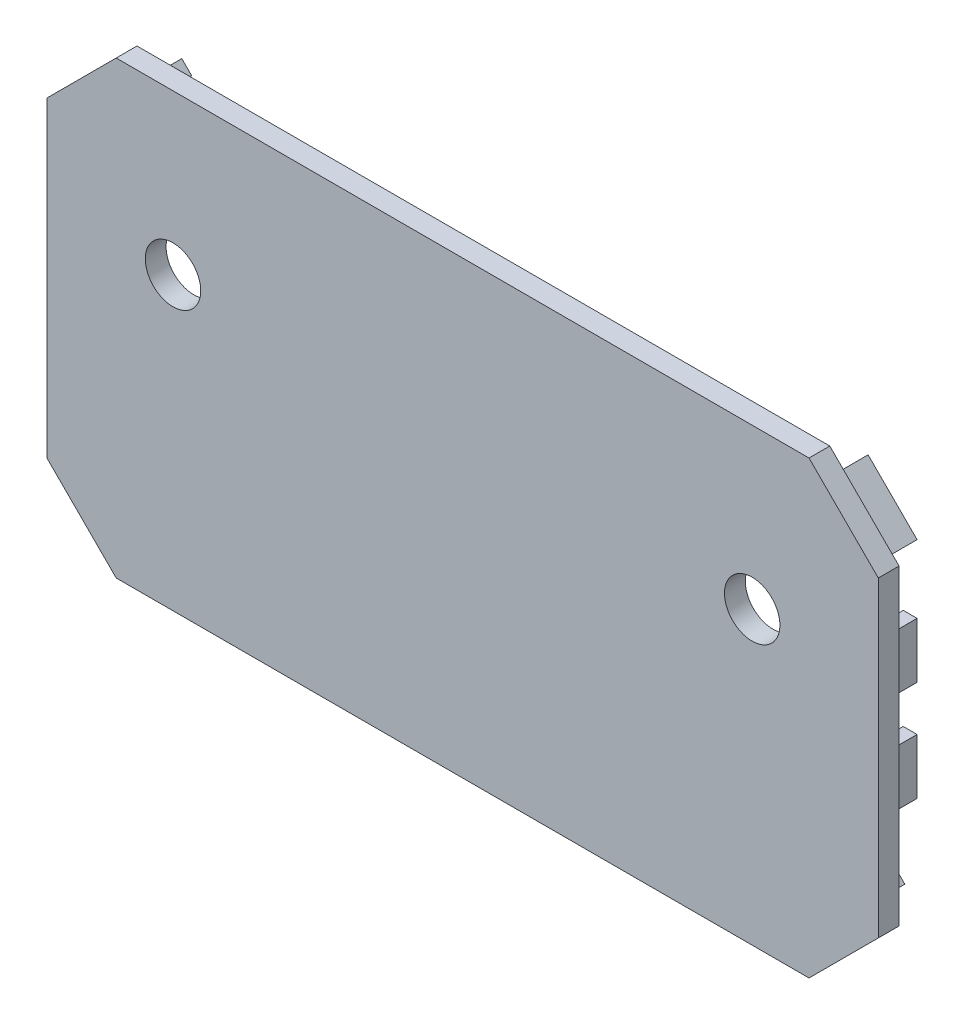
from build123d import *

# Parameters (mm, degrees)
SKETCH1_W           = 120
SKETCH1_H           = 65
BOSS_EXTRUDE1_DEPTH = 3
CHAMFER1_SIZE       = 10
SKETCH2_W           = 2
SKETCH2_H           = 8
BOSS_EXTRUDE3_DEPTH = 6
CHAMFER2_SIZE       = 4
SKETCH4_R           = 4
CUT_EXTRUDE1_DEPTH  = 6


with BuildPart() as part:
    # Sketch1 → Boss-Extrude1 (new body)
    with BuildSketch(Plane.XY):
        with Locations((60, 32.5)):
            Rectangle(SKETCH1_W, SKETCH1_H)
    extrude(amount=BOSS_EXTRUDE1_DEPTH)

    # Chamfer1
    chamfer1_edges = [part.edges().sort_by_distance(p)[0] for p in [
        (0, 65, 1.5),
        (120, 65, 1.5),
        (120, 0, 1.5),
        (0, 0, 1.5),
    ]]
    chamfer(chamfer1_edges, length=CHAMFER1_SIZE)

    # Sketch2 → Boss-Extrude3 (add)
    with BuildSketch(Plane(origin=(0, 0, 0), x_dir=(-1, 0, 0), z_dir=(0, 0, -1))):
        with Locations((-115.6, 25.242640687)):
            Rectangle(SKETCH2_W, SKETCH2_H)
        with Locations((-115.6, 39.757359313)):
            Rectangle(SKETCH2_W, SKETCH2_H)
        Polygon((-109.528932188, 60.6627417), (-116.6, 53.591673888), (-115.185786438, 52.177460326), (-108.114718626, 59.248528137), align=None)
        Polygon((-11.885281374, 59.248528137), (-10.471067812, 60.6627417), (-3.4, 53.591673888), (-4.814213562, 52.177460326), align=None)
        with Locations((-4.4, 25.242640687)):
            Rectangle(SKETCH2_W, SKETCH2_H)
        with Locations((-4.4, 39.757359313)):
            Rectangle(SKETCH2_W, SKETCH2_H)
        Polygon((-114.834314575, 9.642640687), (-113.420101013, 11.056854249), (-107.763246763, 5.4), (-95.763246763, 5.4), (-95.763246763, 3.4), (-108.591673888, 3.4), align=None)
        Polygon((-11.408326112, 3.4), (-5.165685425, 9.642640687), (-6.579898987, 11.056854249), (-12.236753237, 5.4), (-24.236753237, 5.4), (-24.236753237, 3.4), align=None)
    extrude(amount=BOSS_EXTRUDE3_DEPTH)

    # Chamfer2
    chamfer2_edges = [part.edges().sort_by_distance(p)[0] for p in [
        (8.349747468, 55.712994231, 0),
        (5.4, 25.242640687, 0),
        (5.4, 39.757359313, 0),
        (114.6, 39.757359313, 0),
        (114.6, 25.242640687, 0),
        (101.763246763, 5.4, 0),
        (110.591673888, 8.228427125, 0),
        (111.650252532, 55.712994231, 0),
        (9.408326112, 8.228427125, 0),
        (18.236753237, 5.4, 0),
    ]]
    chamfer(chamfer2_edges, length=CHAMFER2_SIZE)

    # Sketch4 → Cut-Extrude1 (cut)
    with BuildSketch(Plane(origin=(0, 0, 0), x_dir=(-1, 0, 0), z_dir=(0, 0, -1))):
        with Locations((-18.2, 42)):
            Circle(SKETCH4_R)
        with Locations((-101.8, 42)):
            Circle(SKETCH4_R)
    extrude(amount=-CUT_EXTRUDE1_DEPTH, mode=Mode.SUBTRACT)


solid = part.part
